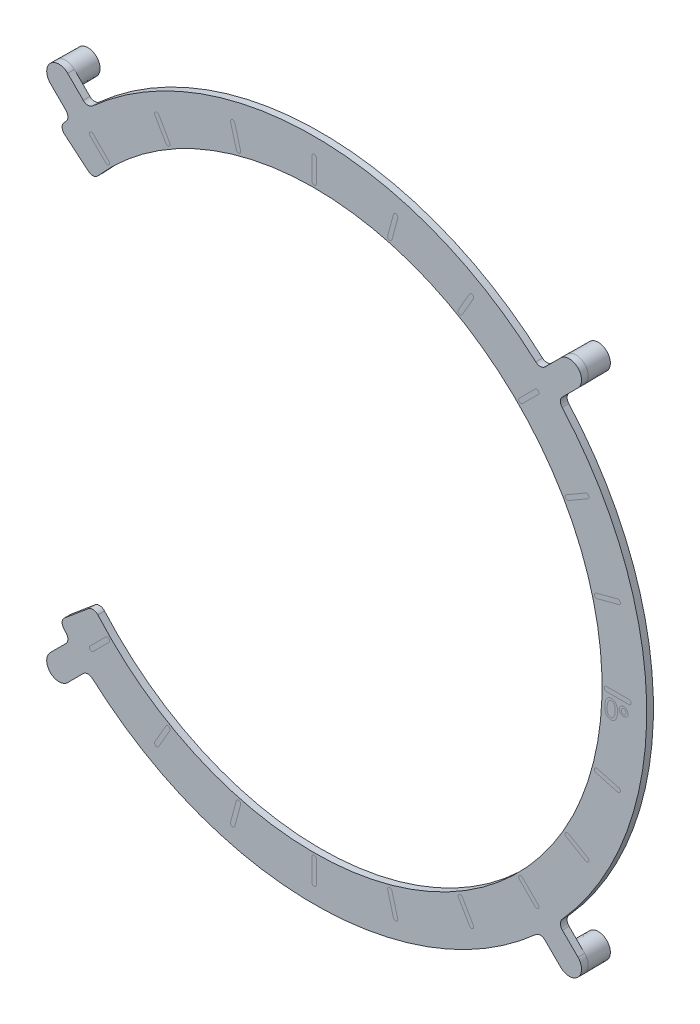
from build123d import *

# Parameters (mm, degrees)
RING_DEPTH               = 3
MAIN_FEATURES_SKETCH_3_R = 5.5
PEGS_DEPTH               = 10
PEGS_DRAFT               = -0.5
PEGS_PROFILE_2_DEPTH     = 10
PEGS_PROFILE_2_DRAFT     = -0.5
PEGS_PROFILE_3_DEPTH     = 10
PEGS_PROFILE_3_DRAFT     = -0.5
PEGS_PROFILE_4_DEPTH     = 10
PEGS_PROFILE_4_DRAFT     = -0.5
FILLET1_R                = 3
CUT_TICKS_DEPTH          = 1
EXTRUDE_TICKS_DEPTH      = 1
EXTRUDE_TICKS_2_DEPTH    = 1
EXTRUDE_TICKS_3_DEPTH    = 1
EXTRUDE_TICKS_4_DEPTH    = 1
EXTRUDE_TICKS_5_DEPTH    = 1
EXTRUDE_TICKS_6_DEPTH    = 1
EXTRUDE_TICKS_7_DEPTH    = 1
EXTRUDE_TICKS_8_DEPTH    = 1
EXTRUDE_TICKS_9_DEPTH    = 1
EXTRUDE_TICKS_10_DEPTH   = 1
EXTRUDE_TICKS_11_DEPTH   = 1
EXTRUDE_TICKS_12_DEPTH   = 1
EXTRUDE_TICKS_13_DEPTH   = 1
EXTRUDE_TICKS_14_DEPTH   = 1
EXTRUDE_TICKS_15_DEPTH   = 1
EXTRUDE_TICKS_16_DEPTH   = 1
EXTRUDE_TICKS_17_DEPTH   = 1
EXTRUDE_TICKS_18_DEPTH   = 1
EXTRUDE_TICKS_19_DEPTH   = 1
CUT_NUMBERS_DEPTH        = 1
EXTRUDE_NUMBERS_DEPTH    = 1
EXTRUDE_NUMBERS_2_DEPTH  = 1


with BuildPart() as part:
    # main_features_sketch → ring (new body)
    with BuildSketch(Plane.XY):
        with BuildLine():
            ThreePointArc((-98.819733162, 82.91960165), (129, 0), (-98.819733162, -82.91960165))
            Line((-98.819733162, -82.91960165), (-114.140622025, -95.775353843))
            ThreePointArc((-114.140622025, -95.775353843), (-111.693794635, -98.617930621), (-109.176194769, -101.398020176))
            Line((-109.176194769, -101.398020176), (-118.189087297, -110.410912703))
            ThreePointArc((-118.189087297, -110.410912703), (-118.189087297, -118.189087297), (-110.410912703, -118.189087297))
            Line((-110.410912703, -118.189087297), (-101.398020176, -109.176194769))
            ThreePointArc((-101.398020176, -109.176194769), (0, -149), (101.398020176, -109.176194769))
            Line((101.398020176, -109.176194769), (110.410912703, -118.189087297))
            ThreePointArc((110.410912703, -118.189087297), (118.189087297, -118.189087297), (118.189087297, -110.410912703))
            Line((118.189087297, -110.410912703), (109.176194769, -101.398020176))
            ThreePointArc((109.176194769, -101.398020176), (149, 0), (109.176194769, 101.398020176))
            Line((109.176194769, 101.398020176), (118.189087297, 110.410912703))
            ThreePointArc((118.189087297, 110.410912703), (118.189087297, 118.189087297), (110.410912703, 118.189087297))
            Line((110.410912703, 118.189087297), (101.398020176, 109.176194769))
            ThreePointArc((101.398020176, 109.176194769), (0, 149), (-101.398020176, 109.176194769))
            Line((-101.398020176, 109.176194769), (-110.410912703, 118.189087297))
            ThreePointArc((-110.410912703, 118.189087297), (-118.189087297, 118.189087297), (-118.189087297, 110.410912703))
            Line((-118.189087297, 110.410912703), (-109.176194769, 101.398020176))
            ThreePointArc((-109.176194769, 101.398020176), (-111.693794635, 98.617930621), (-114.140622025, 95.775353843))
            Line((-114.140622025, 95.775353843), (-98.819733162, 82.91960165))
        make_face()
    extrude(amount=RING_DEPTH)


with BuildPart() as pegs_tool:
    # main_features_sketch_3 → pegs (with draft: the straight prism first)
    with BuildSketch(Plane.XY):
        with Locations((-114.3, -114.3)):
            Circle(MAIN_FEATURES_SKETCH_3_R)
    extrude(amount=-PEGS_DEPTH)
    # pegs: the draft: its side faces are tilted about the plane it starts from
    pegs_sides = [pegs_tool.faces().sort_by_distance(p)[0] for p in [
        (-119.8, -114.3, -5),
    ]]
    draft(pegs_sides, Plane.XY, PEGS_DRAFT)


with BuildPart() as part_1:
    add(part.part)

    # pegs: add pegs_tool
    add(pegs_tool.part)


with BuildPart() as pegs_profile_2_tool:
    # main_features_sketch_3 → pegs profile 2 (with draft: the straight prism first)
    with BuildSketch(Plane.XY):
        with Locations((-114.3, 114.3)):
            Circle(MAIN_FEATURES_SKETCH_3_R)
    extrude(amount=-PEGS_PROFILE_2_DEPTH)
    # pegs profile 2: the draft: its side faces are tilted about the plane it starts from
    pegs_profile_2_sides = [pegs_profile_2_tool.faces().sort_by_distance(p)[0] for p in [
        (-119.8, 114.3, -5),
    ]]
    draft(pegs_profile_2_sides, Plane.XY, PEGS_PROFILE_2_DRAFT)


with BuildPart() as part_2:
    add(part_1.part)

    # pegs profile 2: add pegs_profile_2_tool
    add(pegs_profile_2_tool.part)


with BuildPart() as pegs_profile_3_tool:
    # main_features_sketch_3 → pegs profile 3 (with draft: the straight prism first)
    with BuildSketch(Plane.XY):
        with Locations((114.3, -114.3)):
            Circle(MAIN_FEATURES_SKETCH_3_R)
    extrude(amount=-PEGS_PROFILE_3_DEPTH)
    # pegs profile 3: the draft: its side faces are tilted about the plane it starts from
    pegs_profile_3_sides = [pegs_profile_3_tool.faces().sort_by_distance(p)[0] for p in [
        (108.8, -114.3, -5),
    ]]
    draft(pegs_profile_3_sides, Plane.XY, PEGS_PROFILE_3_DRAFT)


with BuildPart() as part_3:
    add(part_2.part)

    # pegs profile 3: add pegs_profile_3_tool
    add(pegs_profile_3_tool.part)


with BuildPart() as pegs_profile_4_tool:
    # main_features_sketch_3 → pegs profile 4 (with draft: the straight prism first)
    with BuildSketch(Plane.XY):
        with Locations((114.3, 114.3)):
            Circle(MAIN_FEATURES_SKETCH_3_R)
    extrude(amount=-PEGS_PROFILE_4_DEPTH)
    # pegs profile 4: the draft: its side faces are tilted about the plane it starts from
    pegs_profile_4_sides = [pegs_profile_4_tool.faces().sort_by_distance(p)[0] for p in [
        (108.8, 114.3, -5),
    ]]
    draft(pegs_profile_4_sides, Plane.XY, PEGS_PROFILE_4_DRAFT)


with BuildPart() as part_4:
    add(part_3.part)

    # pegs profile 4: add pegs_profile_4_tool
    add(pegs_profile_4_tool.part)

    # Fillet1
    fillet1_edges = [part_4.edges().sort_by_distance(p)[0] for p in [
        (-98.819733162, -82.91960165, 1.5),
        (-114.140622025, -95.775353843, 1.5),
        (-109.176194769, -101.398020176, 1.5),
        (-101.398020176, -109.176194769, 1.5),
        (101.398020176, -109.176194769, 1.5),
        (109.176194769, -101.398020176, 1.5),
        (109.176194769, 101.398020176, 1.5),
        (101.398020176, 109.176194769, 1.5),
        (-98.819733162, 82.91960165, 1.5),
        (-114.140622025, 95.775353843, 1.5),
        (-101.398020176, 109.176194769, 1.5),
        (-109.176194769, 101.398020176, 1.5),
    ]]
    fillet(fillet1_edges, radius=FILLET1_R)

    # tick_marks → cut_ticks (cut)
    with BuildSketch(Plane.XY.offset(3)):
        with BuildLine():
            Line((-93.338095117, 91.923881554), (-100.409162928, 98.994949366))
            ThreePointArc((-100.409162928, 98.994949366), (-100.409162928, 100.409162928), (-98.994949366, 100.409162928))
            Line((-98.994949366, 100.409162928), (-91.923881554, 93.338095117))
            ThreePointArc((-91.923881554, 93.338095117), (-91.923881554, 91.923881554), (-93.338095117, 91.923881554))
        make_face()
        with BuildLine():
            Line((-66.366025404, 112.949327896), (-71.366025404, 121.609581934))
            ThreePointArc((-71.366025404, 121.609581934), (-71, 122.975607337), (-69.633974596, 122.609581934))
            Line((-69.633974596, 122.609581934), (-64.633974596, 113.949327896))
            ThreePointArc((-64.633974596, 113.949327896), (-65, 112.583302492), (-66.366025404, 112.949327896))
        make_face()
        with BuildLine():
            Line((-34.871220735, 126.277464199), (-37.459411186, 135.936722462))
            ThreePointArc((-37.459411186, 135.936722462), (-36.752304405, 137.161467333), (-35.527559533, 136.454360552))
            Line((-35.527559533, 136.454360552), (-32.939369082, 126.795102289))
            ThreePointArc((-32.939369082, 126.795102289), (-33.646475863, 125.570357418), (-34.871220735, 126.277464199))
        make_face()
        with BuildLine():
            Line((-1, 131), (-1, 141))
            ThreePointArc((-1, 141), (0, 142), (1, 141))
            Line((1, 141), (1, 131))
            ThreePointArc((1, 131), (0, 130), (-1, 131))
        make_face()
        with BuildLine():
            Line((32.939369082, 126.795102289), (35.527559533, 136.454360552))
            ThreePointArc((35.527559533, 136.454360552), (36.752304405, 137.161467333), (37.459411186, 135.936722462))
            Line((37.459411186, 135.936722462), (34.871220735, 126.277464199))
            ThreePointArc((34.871220735, 126.277464199), (33.646475863, 125.570357418), (32.939369082, 126.795102289))
        make_face()
        with BuildLine():
            Line((64.633974596, 113.949327896), (69.633974596, 122.609581934))
            ThreePointArc((69.633974596, 122.609581934), (71, 122.975607337), (71.366025404, 121.609581934))
            Line((71.366025404, 121.609581934), (66.366025404, 112.949327896))
            ThreePointArc((66.366025404, 112.949327896), (65, 112.583302492), (64.633974596, 113.949327896))
        make_face()
        with BuildLine():
            Line((91.923881554, 93.338095117), (98.994949366, 100.409162928))
            ThreePointArc((98.994949366, 100.409162928), (100.409162928, 100.409162928), (100.409162928, 98.994949366))
            Line((100.409162928, 98.994949366), (93.338095117, 91.923881554))
            ThreePointArc((93.338095117, 91.923881554), (91.923881554, 91.923881554), (91.923881554, 93.338095117))
        make_face()
        with BuildLine():
            Line((112.949327896, 66.366025404), (121.609581934, 71.366025404))
            ThreePointArc((121.609581934, 71.366025404), (122.975607337, 71), (122.609581934, 69.633974596))
            Line((122.609581934, 69.633974596), (113.949327896, 64.633974596))
            ThreePointArc((113.949327896, 64.633974596), (112.583302492, 65), (112.949327896, 66.366025404))
        make_face()
        with BuildLine():
            Line((126.277464199, 34.871220735), (135.936722462, 37.459411186))
            ThreePointArc((135.936722462, 37.459411186), (137.161467333, 36.752304405), (136.454360552, 35.527559533))
            Line((136.454360552, 35.527559533), (126.795102289, 32.939369082))
            ThreePointArc((126.795102289, 32.939369082), (125.570357418, 33.646475863), (126.277464199, 34.871220735))
        make_face()
        with BuildLine():
            Line((131, 1), (141, 1))
            ThreePointArc((141, 1), (142, 0), (141, -1))
            Line((141, -1), (131, -1))
            ThreePointArc((131, -1), (130, 0), (131, 1))
        make_face()
        with BuildLine():
            Line((126.795102289, -32.939369082), (136.454360552, -35.527559533))
            ThreePointArc((136.454360552, -35.527559533), (137.161467333, -36.752304405), (135.936722462, -37.459411186))
            Line((135.936722462, -37.459411186), (126.277464199, -34.871220735))
            ThreePointArc((126.277464199, -34.871220735), (125.570357418, -33.646475863), (126.795102289, -32.939369082))
        make_face()
        with BuildLine():
            Line((113.949327896, -64.633974596), (122.609581934, -69.633974596))
            ThreePointArc((122.609581934, -69.633974596), (122.975607337, -71), (121.609581934, -71.366025404))
            Line((121.609581934, -71.366025404), (112.949327896, -66.366025404))
            ThreePointArc((112.949327896, -66.366025404), (112.583302492, -65), (113.949327896, -64.633974596))
        make_face()
        with BuildLine():
            Line((93.338095117, -91.923881554), (100.409162928, -98.994949366))
            ThreePointArc((100.409162928, -98.994949366), (100.409162928, -100.409162928), (98.994949366, -100.409162928))
            Line((98.994949366, -100.409162928), (91.923881554, -93.338095117))
            ThreePointArc((91.923881554, -93.338095117), (91.923881554, -91.923881554), (93.338095117, -91.923881554))
        make_face()
        with BuildLine():
            Line((66.366025404, -112.949327896), (71.366025404, -121.609581934))
            ThreePointArc((71.366025404, -121.609581934), (71, -122.975607337), (69.633974596, -122.609581934))
            Line((69.633974596, -122.609581934), (64.633974596, -113.949327896))
            ThreePointArc((64.633974596, -113.949327896), (65, -112.583302492), (66.366025404, -112.949327896))
        make_face()
        with BuildLine():
            Line((34.871220735, -126.277464199), (37.459411186, -135.936722462))
            ThreePointArc((37.459411186, -135.936722462), (36.752304405, -137.161467333), (35.527559533, -136.454360552))
            Line((35.527559533, -136.454360552), (32.939369082, -126.795102289))
            ThreePointArc((32.939369082, -126.795102289), (33.646475863, -125.570357418), (34.871220735, -126.277464199))
        make_face()
        with BuildLine():
            Line((1, -131), (1, -141))
            ThreePointArc((1, -141), (0, -142), (-1, -141))
            Line((-1, -141), (-1, -131))
            ThreePointArc((-1, -131), (0, -130), (1, -131))
        make_face()
        with BuildLine():
            Line((-32.939369082, -126.795102289), (-35.527559533, -136.454360552))
            ThreePointArc((-35.527559533, -136.454360552), (-36.752304405, -137.161467333), (-37.459411186, -135.936722462))
            Line((-37.459411186, -135.936722462), (-34.871220735, -126.277464199))
            ThreePointArc((-34.871220735, -126.277464199), (-33.646475863, -125.570357418), (-32.939369082, -126.795102289))
        make_face()
        with BuildLine():
            Line((-64.633974596, -113.949327896), (-69.633974596, -122.609581934))
            ThreePointArc((-69.633974596, -122.609581934), (-71, -122.975607337), (-71.366025404, -121.609581934))
            Line((-71.366025404, -121.609581934), (-66.366025404, -112.949327896))
            ThreePointArc((-66.366025404, -112.949327896), (-65, -112.583302492), (-64.633974596, -113.949327896))
        make_face()
        with BuildLine():
            Line((-91.923881554, -93.338095117), (-98.994949366, -100.409162928))
            ThreePointArc((-98.994949366, -100.409162928), (-100.409162928, -100.409162928), (-100.409162928, -98.994949366))
            Line((-100.409162928, -98.994949366), (-93.338095117, -91.923881554))
            ThreePointArc((-93.338095117, -91.923881554), (-91.923881554, -91.923881554), (-91.923881554, -93.338095117))
        make_face()
    extrude(amount=-CUT_TICKS_DEPTH, mode=Mode.SUBTRACT)

    # numbers_sketch → cut_numbers (cut)
    # profile 1 of 2: a face of its own
    with BuildSketch(Plane.XY.offset(3)):
        with BuildLine():
            add(Edge.make_bspline(
                [(130.247849847, -6.530142484), (130.259435363, -6.403469593), (130.281956239, -6.157232438), (130.326358515, -5.799510621), (130.381168679, -5.46451119), (130.442355031, -5.1518788), (130.515029315, -4.862814833), (130.594128584, -4.595899097), (130.683995641, -4.352014642), (130.782001058, -4.12854355), (130.890269218, -3.924103907), (131.005785678, -3.734961692), (131.127740313, -3.558505709), (131.259619838, -3.396759959), (131.398720167, -3.24721496), (131.546540196, -3.112007382), (131.702941503, -2.991527308), (131.866051533, -2.883833986), (132.035501194, -2.791899136), (132.208036711, -2.712073639), (132.384525467, -2.648197637), (132.564527725, -2.598227156), (132.748335202, -2.562873772), (132.935320966, -2.541751072), (133.126165442, -2.53729926), (133.253751824, -2.544250514), (133.318362667, -2.547770689)],
                knots=[0, 0, 0, 0, 1.61827603, 3.145737672, 4.584824523, 5.936336854, 7.197309618, 8.375551137, 9.476458172, 10.501880003, 11.477750075, 12.417205866, 13.320287874, 14.204452368, 15.069952981, 15.916623796, 16.749932666, 17.579324636, 18.400517487, 19.200339989, 19.995819531, 20.785617524, 21.574684155, 22.37473762, 23.176953122, 24, 24, 24, 24], degree=3))
            add(Edge.make_bspline(
                [(133.318362667, -2.547770689), (133.387940092, -2.554757524), (133.525714067, -2.568592528), (133.728496495, -2.607156697), (133.924047373, -2.662551136), (134.113647764, -2.729144897), (134.29542451, -2.811146872), (134.469524417, -2.908590774), (134.637917985, -3.018480634), (134.797906464, -3.144270734), (134.950544053, -3.281391991), (135.091373365, -3.432616918), (135.222039496, -3.595493891), (135.342123787, -3.770875134), (135.453483832, -3.958015713), (135.550207869, -4.159466414), (135.63869308, -4.371748217), (135.718110412, -4.596510255), (135.783160952, -4.837201101), (135.838549624, -5.093720763), (135.87670579, -5.368100731), (135.906727666, -5.659338124), (135.919992298, -5.968042543), (135.920742748, -6.294076198), (135.912395875, -6.637354245), (135.894731769, -6.871544848), (135.88567036, -6.991680945)],
                knots=[0, 0, 0, 0, 0.871311131, 1.725329718, 2.568587105, 3.402540465, 4.227998323, 5.05060485, 5.887158929, 6.731572112, 7.584785719, 8.44212009, 9.304147133, 10.185097487, 11.089488333, 12.01557912, 12.967704211, 13.955299893, 14.984247638, 16.073349664, 17.224008303, 18.435090282, 19.721522675, 21.07315721, 22.498575664, 24, 24, 24, 24], degree=3))
            add(Edge.make_bspline(
                [(135.88567036, -6.991680945), (135.87479058, -7.111433308), (135.853622099, -7.344432114), (135.808150516, -7.683801219), (135.754498147, -8.003626595), (135.690263875, -8.304664383), (135.616825808, -8.586557955), (135.534820573, -8.84998105), (135.438847324, -9.092572725), (135.33733295, -9.318194204), (135.223423739, -9.525855289), (135.103669775, -9.720872102), (134.973777637, -9.901606703), (134.836110104, -10.069655895), (134.687111833, -10.22168589), (134.532441813, -10.36391007), (134.366830345, -10.490301351), (134.193660138, -10.602639646), (134.013959435, -10.700182365), (133.829586648, -10.78437933), (133.639932775, -10.850995812), (133.446407353, -10.905127237), (133.247914075, -10.941455232), (133.045384402, -10.962357825), (132.838520935, -10.967298234), (132.699742911, -10.959024201), (132.629260103, -10.954821971)],
                knots=[0, 0, 0, 0, 1.499152549, 2.916858956, 4.268090621, 5.541798329, 6.75344151, 7.899374152, 8.979171957, 10.00447148, 10.982037653, 11.930231764, 12.856270518, 13.75513052, 14.635967874, 15.508302836, 16.372898767, 17.230125775, 18.079580563, 18.920215607, 19.754467163, 20.583410652, 21.423412171, 22.267102547, 23.119893245, 24, 24, 24, 24], degree=3))
            add(Edge.make_bspline(
                [(132.629260103, -10.954821971), (132.564456808, -10.948498714), (132.436738356, -10.936036438), (132.24956895, -10.897456399), (132.068054374, -10.848766349), (131.893081397, -10.784046791), (131.724081193, -10.706450737), (131.560161102, -10.617603367), (131.404002808, -10.511730075), (131.25372322, -10.394295281), (131.112388011, -10.261708946), (130.979545005, -10.118091256), (130.856405818, -9.961299831), (130.745499206, -9.790719069), (130.640015566, -9.609903088), (130.548071068, -9.415188381), (130.463963446, -9.208895706), (130.390118693, -8.988531822), (130.326932554, -8.751103431), (130.277982734, -8.494002622), (130.241341289, -8.216293828), (130.218544477, -7.918313275), (130.20473238, -7.600252795), (130.208234406, -7.261870953), (130.220018393, -6.902662908), (130.238394951, -6.656695046), (130.247849847, -6.530142484)],
                knots=[0, 0, 0, 0, 0.828437702, 1.632737654, 2.42967114, 3.219345181, 4.004554763, 4.795954934, 5.590097458, 6.403746225, 7.221817338, 8.054487758, 8.892584602, 9.756526925, 10.643140985, 11.55574709, 12.495399042, 13.478287074, 14.512653996, 15.621085901, 16.808049767, 18.077183614, 19.424923863, 20.859997346, 22.384441863, 24, 24, 24, 24], degree=3))
        make_face()
        with BuildLine():
            add(Edge.make_bspline(
                [(131.292721642, -6.631104022), (131.28477992, -6.737910983), (131.269382673, -6.944986108), (131.25459966, -7.246337634), (131.249374469, -7.528005474), (131.254212577, -7.789378752), (131.266793287, -8.030464885), (131.286683691, -8.251482431), (131.316739715, -8.452803405), (131.356925286, -8.635255481), (131.405956699, -8.802366562), (131.460480848, -8.957275101), (131.518809789, -9.10274443), (131.587059103, -9.236021753), (131.660081725, -9.359772425), (131.740979543, -9.472492821), (131.827042298, -9.575610218), (131.949485678, -9.694946681), (132.110097593, -9.820135734), (132.311713463, -9.935468713), (132.518229181, -10.015352986), (132.660158763, -10.034910892), (132.730221642, -10.044565561)],
                knots=[0, 0, 0, 0, 1.562818808, 3.029960774, 4.40208351, 5.672886883, 6.843801576, 7.924276773, 8.909845954, 9.811982668, 10.648232427, 11.449452758, 12.207976657, 12.933081093, 13.632246986, 14.302799925, 14.955536824, 15.589430577, 16.794738237, 17.915324831, 18.970909793, 20, 20, 20, 20], degree=3))
            add(Edge.make_bspline(
                [(132.730221642, -10.044565561), (132.811050679, -10.047619097), (132.971788916, -10.053691421), (133.211816457, -10.008101791), (133.446049671, -9.926027653), (133.633444874, -9.823758572), (133.778602522, -9.723991846), (133.883046034, -9.634662025), (133.982736116, -9.535479424), (134.075767197, -9.423879353), (134.163508035, -9.301946178), (134.247645318, -9.169616626), (134.32584787, -9.026129116), (134.371878597, -8.924679488), (134.395285744, -8.873091202)],
                knots=[0, 0, 0, 0, 1.331768172, 2.648380761, 4.004028281, 5.416743492, 6.158066992, 6.909033705, 7.682352155, 8.477345272, 9.304749422, 10.161119474, 11.064908395, 12, 12, 12, 12], degree=3))
            add(Edge.make_bspline(
                [(134.395285744, -8.873091202), (134.424437914, -8.805044135), (134.483471319, -8.667248211), (134.557922605, -8.450389586), (134.626708345, -8.223844279), (134.688294147, -7.985617854), (134.738854639, -7.735621101), (134.781225821, -7.474588221), (134.819703291, -7.202852125), (134.835791851, -7.017418695), (134.844003693, -6.922770689)],
                knots=[0, 0, 0, 0, 0.883430991, 1.788955713, 2.735063933, 3.709438727, 4.72492913, 5.778506935, 6.866116603, 8, 8, 8, 8], degree=3))
            add(Edge.make_bspline(
                [(134.844003693, -6.922770689), (134.851103131, -6.828257802), (134.864969864, -6.64365375), (134.873709603, -6.373165985), (134.876386913, -6.11555067), (134.86787141, -5.870745012), (134.852608077, -5.638102235), (134.827437212, -5.418713513), (134.791580864, -5.212443577), (134.749082217, -5.018596941), (134.69705082, -4.837068702), (134.640509196, -4.66680481), (134.573997308, -4.509365326), (134.502609593, -4.36329577), (134.423516387, -4.229566617), (134.339005199, -4.107433605), (134.247036631, -3.997136325), (134.116799505, -3.869984638), (133.944635744, -3.736224846), (133.727051925, -3.612467068), (133.50007645, -3.528059555), (133.343574914, -3.506998469), (133.265478052, -3.496488638)],
                knots=[0, 0, 0, 0, 1.357865668, 2.652204481, 3.876866366, 5.048551581, 6.161015914, 7.216739124, 8.210814996, 9.159724225, 10.058636074, 10.915472518, 11.728562328, 12.505583417, 13.243310273, 13.952492572, 14.631630308, 15.297351225, 16.557379802, 17.743155118, 18.873796981, 20, 20, 20, 20], degree=3))
            add(Edge.make_bspline(
                [(133.265478052, -3.496488638), (133.194273069, -3.495026174), (133.050624281, -3.492075803), (132.833369163, -3.534923422), (132.617078694, -3.616817065), (132.441028499, -3.715419587), (132.301367285, -3.811035844), (132.200658471, -3.898336419), (132.104377543, -3.996992509), (132.011109656, -4.105358517), (131.924374985, -4.227257476), (131.841591908, -4.360343558), (131.761030173, -4.50407286), (131.686884278, -4.661567376), (131.61704085, -4.835174682), (131.553386473, -5.028938426), (131.49661813, -5.244332434), (131.443185207, -5.480421437), (131.397970387, -5.738406918), (131.355878319, -6.017227168), (131.321204333, -6.317170633), (131.302418773, -6.524223207), (131.292721642, -6.631104022)],
                knots=[0, 0, 0, 0, 1.037413375, 2.092875636, 3.208354798, 4.402221346, 5.029658683, 5.676805883, 6.344129212, 7.041189164, 7.761973708, 8.525859314, 9.328838035, 10.166119681, 11.065501841, 12.059435704, 13.141589609, 14.316608638, 15.592490277, 16.964620918, 18.433133255, 20, 20, 20, 20], degree=3))
        make_face(mode=Mode.SUBTRACT)
    # profile 2 of 2: a face of its own
    with BuildSketch(Plane.XY.offset(3)):
        with BuildLine():
            add(Edge.make_bspline(
                [(140.640846808, -5.083838614), (140.633383432, -5.147562419), (140.618591458, -5.273859266), (140.57766023, -5.45869898), (140.514810374, -5.634381204), (140.439301208, -5.803853851), (140.34095109, -5.96325836), (140.227677777, -6.115436223), (140.095943209, -6.259576437), (139.948976911, -6.393630193), (139.789189417, -6.515781224), (139.619421776, -6.619781176), (139.4419086, -6.705676525), (139.256534952, -6.771788407), (139.063492644, -6.817646528), (138.862986835, -6.847119571), (138.65468573, -6.856574516), (138.513684624, -6.848934), (138.442128859, -6.845056563)],
                knots=[0, 0, 0, 0, 0.981834128, 1.945937709, 2.889855742, 3.833915441, 4.780521496, 5.750329985, 6.734374955, 7.764627895, 8.791695718, 9.808458087, 10.806904893, 11.805251239, 12.814753756, 13.839344671, 14.903502628, 16, 16, 16, 16], degree=3))
            add(Edge.make_bspline(
                [(138.442128859, -6.845056563), (138.3762364, -6.83771889), (138.246154529, -6.823233193), (138.056818787, -6.780855519), (137.876085319, -6.723594766), (137.705094317, -6.647934942), (137.544275675, -6.553712959), (137.390934658, -6.444868658), (137.248328695, -6.31727615), (137.115896638, -6.175105874), (136.99651935, -6.021639253), (136.895204612, -5.858574152), (136.810876705, -5.689942624), (136.746570779, -5.513467071), (136.700053627, -5.330333692), (136.671588582, -5.140351196), (136.659170472, -4.943360499), (136.66720125, -4.810319714), (136.671295526, -4.74249246)],
                knots=[0, 0, 0, 0, 1.037515882, 2.048216267, 3.032259203, 4.002157969, 4.969130722, 5.946359887, 6.941784324, 7.959727494, 8.985339925, 9.981045476, 10.961134342, 11.932330728, 12.916267007, 13.914709271, 14.93687081, 16, 16, 16, 16], degree=3))
            add(Edge.make_bspline(
                [(136.671295526, -4.74249246), (136.677767486, -4.677606349), (136.690509742, -4.549855943), (136.735993984, -4.36464513), (136.794257544, -4.187484416), (136.872098918, -4.019423224), (136.967542562, -3.860636827), (137.077903886, -3.708274039), (137.20939817, -3.56790073), (137.354025972, -3.435307735), (137.510576958, -3.316527414), (137.67502347, -3.215010643), (137.844373516, -3.130854419), (138.019683514, -3.064358268), (138.20106051, -3.018529045), (138.387169616, -2.989494599), (138.578874754, -2.977186556), (138.708171714, -2.985210735), (138.773859629, -2.989287332)],
                knots=[0, 0, 0, 0, 1.027633626, 2.023246725, 3.001404518, 3.966806442, 4.93815026, 5.920944928, 6.929002123, 7.967089793, 9.013899898, 10.024350194, 11.011903836, 11.993432784, 12.976697161, 13.957755568, 14.962459916, 16, 16, 16, 16], degree=3))
            add(Edge.make_bspline(
                [(138.773859629, -2.989287332), (138.844609543, -2.996288336), (138.983518872, -3.010034001), (139.1848429, -3.056791183), (139.376320244, -3.117518385), (139.558778832, -3.19383836), (139.729342691, -3.2908165), (139.888439224, -3.405806434), (140.038605181, -3.535702465), (140.175042957, -3.682664608), (140.296750208, -3.839971585), (140.404410463, -4.002307927), (140.491172872, -4.17117685), (140.558225053, -4.344967655), (140.6092626, -4.522819156), (140.639141832, -4.705618981), (140.650912798, -4.893620809), (140.644238443, -5.019746629), (140.640846808, -5.083838614)],
                knots=[0, 0, 0, 0, 1.092231102, 2.144470277, 3.170607154, 4.179101014, 5.179634945, 6.180371174, 7.193437818, 8.227924729, 9.258163217, 10.249244673, 11.219129963, 12.17100311, 13.109778343, 14.05913166, 15.013730062, 16, 16, 16, 16], degree=3))
        make_face()
        with BuildLine():
            add(Edge.make_bspline(
                [(139.701744244, -5.018133486), (139.704876527, -4.937324657), (139.710962569, -4.780312662), (139.667640538, -4.551312289), (139.582926193, -4.340714373), (139.459309251, -4.152824167), (139.307022574, -3.992054538), (139.129030317, -3.869780827), (138.93055216, -3.785174599), (138.788552121, -3.766456914), (138.716167321, -3.756915537)],
                knots=[0, 0, 0, 0, 1.086947956, 2.111945782, 3.113135014, 4.127384682, 5.12523017, 6.077643061, 7.020074749, 8, 8, 8, 8], degree=3))
            add(Edge.make_bspline(
                [(138.716167321, -3.756915537), (138.652843959, -3.755479323), (138.526415764, -3.75261185), (138.339036648, -3.803615965), (138.158200287, -3.892310574), (137.987706306, -4.019404255), (137.836632603, -4.180247948), (137.718806256, -4.373320705), (137.64099883, -4.595277278), (137.620819797, -4.753648457), (137.61039809, -4.835441178)],
                knots=[0, 0, 0, 0, 0.884197212, 1.765343047, 2.689991306, 3.696769463, 4.730306579, 5.76576923, 6.846104338, 8, 8, 8, 8], degree=3))
            add(Edge.make_bspline(
                [(137.61039809, -4.835441178), (137.607117392, -4.916827006), (137.60078455, -5.073928825), (137.645469332, -5.302187887), (137.726047904, -5.513264337), (137.853237266, -5.696282558), (138.000040352, -5.852038311), (138.163365805, -5.969745434), (138.336399187, -6.052730607), (138.459455761, -6.07029551), (138.5206545, -6.079030922)],
                knots=[0, 0, 0, 0, 1.144565006, 2.209392605, 3.253925162, 4.306514957, 5.32904796, 6.256924028, 7.133129998, 8, 8, 8, 8], degree=3))
            add(Edge.make_bspline(
                [(138.5206545, -6.079030922), (138.593009269, -6.081193711), (138.735175488, -6.085443267), (138.944151316, -6.035710353), (139.139915995, -5.944171585), (139.317850371, -5.8104264), (139.471562134, -5.646426051), (139.592168257, -5.456911549), (139.670391656, -5.244511796), (139.691156171, -5.094583636), (139.701744244, -5.018133486)],
                knots=[0, 0, 0, 0, 0.982689701, 1.930837199, 2.894666778, 3.909290256, 4.94438296, 5.941946532, 6.950574092, 8, 8, 8, 8], degree=3))
        make_face(mode=Mode.SUBTRACT)
    extrude(amount=-CUT_NUMBERS_DEPTH, mode=Mode.SUBTRACT)


with BuildPart() as body_2:
    # tick_marks_3 → extrude_ticks (new body)
    with BuildSketch(Plane.XY.offset(3)):
        with BuildLine():
            Line((-93.338095117, 91.923881554), (-100.409162928, 98.994949366))
            ThreePointArc((-100.409162928, 98.994949366), (-100.409162928, 100.409162928), (-98.994949366, 100.409162928))
            Line((-98.994949366, 100.409162928), (-91.923881554, 93.338095117))
            ThreePointArc((-91.923881554, 93.338095117), (-91.923881554, 91.923881554), (-93.338095117, 91.923881554))
        make_face()
    extrude(amount=-EXTRUDE_TICKS_DEPTH)


with BuildPart() as body_3:
    # tick_marks_3 → extrude_ticks 2 (new body)
    with BuildSketch(Plane.XY.offset(3)):
        with BuildLine():
            Line((-66.366025404, 112.949327896), (-71.366025404, 121.609581934))
            ThreePointArc((-71.366025404, 121.609581934), (-71, 122.975607337), (-69.633974596, 122.609581934))
            Line((-69.633974596, 122.609581934), (-64.633974596, 113.949327896))
            ThreePointArc((-64.633974596, 113.949327896), (-65, 112.583302492), (-66.366025404, 112.949327896))
        make_face()
    extrude(amount=-EXTRUDE_TICKS_2_DEPTH)


with BuildPart() as body_4:
    # tick_marks_3 → extrude_ticks 3 (new body)
    with BuildSketch(Plane.XY.offset(3)):
        with BuildLine():
            Line((-34.871220735, 126.277464199), (-37.459411186, 135.936722462))
            ThreePointArc((-37.459411186, 135.936722462), (-36.752304405, 137.161467333), (-35.527559533, 136.454360552))
            Line((-35.527559533, 136.454360552), (-32.939369082, 126.795102289))
            ThreePointArc((-32.939369082, 126.795102289), (-33.646475863, 125.570357418), (-34.871220735, 126.277464199))
        make_face()
    extrude(amount=-EXTRUDE_TICKS_3_DEPTH)


with BuildPart() as body_5:
    # tick_marks_3 → extrude_ticks 4 (new body)
    with BuildSketch(Plane.XY.offset(3)):
        with BuildLine():
            Line((-1, 131), (-1, 141))
            ThreePointArc((-1, 141), (0, 142), (1, 141))
            Line((1, 141), (1, 131))
            ThreePointArc((1, 131), (0, 130), (-1, 131))
        make_face()
    extrude(amount=-EXTRUDE_TICKS_4_DEPTH)


with BuildPart() as body_6:
    # tick_marks_3 → extrude_ticks 5 (new body)
    with BuildSketch(Plane.XY.offset(3)):
        with BuildLine():
            Line((32.939369082, 126.795102289), (35.527559533, 136.454360552))
            ThreePointArc((35.527559533, 136.454360552), (36.752304405, 137.161467333), (37.459411186, 135.936722462))
            Line((37.459411186, 135.936722462), (34.871220735, 126.277464199))
            ThreePointArc((34.871220735, 126.277464199), (33.646475863, 125.570357418), (32.939369082, 126.795102289))
        make_face()
    extrude(amount=-EXTRUDE_TICKS_5_DEPTH)


with BuildPart() as body_7:
    # tick_marks_3 → extrude_ticks 6 (new body)
    with BuildSketch(Plane.XY.offset(3)):
        with BuildLine():
            Line((64.633974596, 113.949327896), (69.633974596, 122.609581934))
            ThreePointArc((69.633974596, 122.609581934), (71, 122.975607337), (71.366025404, 121.609581934))
            Line((71.366025404, 121.609581934), (66.366025404, 112.949327896))
            ThreePointArc((66.366025404, 112.949327896), (65, 112.583302492), (64.633974596, 113.949327896))
        make_face()
    extrude(amount=-EXTRUDE_TICKS_6_DEPTH)


with BuildPart() as body_8:
    # tick_marks_3 → extrude_ticks 7 (new body)
    with BuildSketch(Plane.XY.offset(3)):
        with BuildLine():
            Line((91.923881554, 93.338095117), (98.994949366, 100.409162928))
            ThreePointArc((98.994949366, 100.409162928), (100.409162928, 100.409162928), (100.409162928, 98.994949366))
            Line((100.409162928, 98.994949366), (93.338095117, 91.923881554))
            ThreePointArc((93.338095117, 91.923881554), (91.923881554, 91.923881554), (91.923881554, 93.338095117))
        make_face()
    extrude(amount=-EXTRUDE_TICKS_7_DEPTH)


with BuildPart() as body_9:
    # tick_marks_3 → extrude_ticks 8 (new body)
    with BuildSketch(Plane.XY.offset(3)):
        with BuildLine():
            Line((112.949327896, 66.366025404), (121.609581934, 71.366025404))
            ThreePointArc((121.609581934, 71.366025404), (122.975607337, 71), (122.609581934, 69.633974596))
            Line((122.609581934, 69.633974596), (113.949327896, 64.633974596))
            ThreePointArc((113.949327896, 64.633974596), (112.583302492, 65), (112.949327896, 66.366025404))
        make_face()
    extrude(amount=-EXTRUDE_TICKS_8_DEPTH)


with BuildPart() as body_10:
    # tick_marks_3 → extrude_ticks 9 (new body)
    with BuildSketch(Plane.XY.offset(3)):
        with BuildLine():
            Line((126.277464199, 34.871220735), (135.936722462, 37.459411186))
            ThreePointArc((135.936722462, 37.459411186), (137.161467333, 36.752304405), (136.454360552, 35.527559533))
            Line((136.454360552, 35.527559533), (126.795102289, 32.939369082))
            ThreePointArc((126.795102289, 32.939369082), (125.570357418, 33.646475863), (126.277464199, 34.871220735))
        make_face()
    extrude(amount=-EXTRUDE_TICKS_9_DEPTH)


with BuildPart() as body_11:
    # tick_marks_3 → extrude_ticks 10 (new body)
    with BuildSketch(Plane.XY.offset(3)):
        with BuildLine():
            Line((131, 1), (141, 1))
            ThreePointArc((141, 1), (142, 0), (141, -1))
            Line((141, -1), (131, -1))
            ThreePointArc((131, -1), (130, 0), (131, 1))
        make_face()
    extrude(amount=-EXTRUDE_TICKS_10_DEPTH)


with BuildPart() as body_12:
    # tick_marks_3 → extrude_ticks 11 (new body)
    with BuildSketch(Plane.XY.offset(3)):
        with BuildLine():
            Line((126.795102289, -32.939369082), (136.454360552, -35.527559533))
            ThreePointArc((136.454360552, -35.527559533), (137.161467333, -36.752304405), (135.936722462, -37.459411186))
            Line((135.936722462, -37.459411186), (126.277464199, -34.871220735))
            ThreePointArc((126.277464199, -34.871220735), (125.570357418, -33.646475863), (126.795102289, -32.939369082))
        make_face()
    extrude(amount=-EXTRUDE_TICKS_11_DEPTH)


with BuildPart() as body_13:
    # tick_marks_3 → extrude_ticks 12 (new body)
    with BuildSketch(Plane.XY.offset(3)):
        with BuildLine():
            Line((113.949327896, -64.633974596), (122.609581934, -69.633974596))
            ThreePointArc((122.609581934, -69.633974596), (122.975607337, -71), (121.609581934, -71.366025404))
            Line((121.609581934, -71.366025404), (112.949327896, -66.366025404))
            ThreePointArc((112.949327896, -66.366025404), (112.583302492, -65), (113.949327896, -64.633974596))
        make_face()
    extrude(amount=-EXTRUDE_TICKS_12_DEPTH)


with BuildPart() as body_14:
    # tick_marks_3 → extrude_ticks 13 (new body)
    with BuildSketch(Plane.XY.offset(3)):
        with BuildLine():
            Line((93.338095117, -91.923881554), (100.409162928, -98.994949366))
            ThreePointArc((100.409162928, -98.994949366), (100.409162928, -100.409162928), (98.994949366, -100.409162928))
            Line((98.994949366, -100.409162928), (91.923881554, -93.338095117))
            ThreePointArc((91.923881554, -93.338095117), (91.923881554, -91.923881554), (93.338095117, -91.923881554))
        make_face()
    extrude(amount=-EXTRUDE_TICKS_13_DEPTH)


with BuildPart() as body_15:
    # tick_marks_3 → extrude_ticks 14 (new body)
    with BuildSketch(Plane.XY.offset(3)):
        with BuildLine():
            Line((66.366025404, -112.949327896), (71.366025404, -121.609581934))
            ThreePointArc((71.366025404, -121.609581934), (71, -122.975607337), (69.633974596, -122.609581934))
            Line((69.633974596, -122.609581934), (64.633974596, -113.949327896))
            ThreePointArc((64.633974596, -113.949327896), (65, -112.583302492), (66.366025404, -112.949327896))
        make_face()
    extrude(amount=-EXTRUDE_TICKS_14_DEPTH)


with BuildPart() as body_16:
    # tick_marks_3 → extrude_ticks 15 (new body)
    with BuildSketch(Plane.XY.offset(3)):
        with BuildLine():
            Line((34.871220735, -126.277464199), (37.459411186, -135.936722462))
            ThreePointArc((37.459411186, -135.936722462), (36.752304405, -137.161467333), (35.527559533, -136.454360552))
            Line((35.527559533, -136.454360552), (32.939369082, -126.795102289))
            ThreePointArc((32.939369082, -126.795102289), (33.646475863, -125.570357418), (34.871220735, -126.277464199))
        make_face()
    extrude(amount=-EXTRUDE_TICKS_15_DEPTH)


with BuildPart() as body_17:
    # tick_marks_3 → extrude_ticks 16 (new body)
    with BuildSketch(Plane.XY.offset(3)):
        with BuildLine():
            Line((1, -131), (1, -141))
            ThreePointArc((1, -141), (0, -142), (-1, -141))
            Line((-1, -141), (-1, -131))
            ThreePointArc((-1, -131), (0, -130), (1, -131))
        make_face()
    extrude(amount=-EXTRUDE_TICKS_16_DEPTH)


with BuildPart() as body_18:
    # tick_marks_3 → extrude_ticks 17 (new body)
    with BuildSketch(Plane.XY.offset(3)):
        with BuildLine():
            Line((-32.939369082, -126.795102289), (-35.527559533, -136.454360552))
            ThreePointArc((-35.527559533, -136.454360552), (-36.752304405, -137.161467333), (-37.459411186, -135.936722462))
            Line((-37.459411186, -135.936722462), (-34.871220735, -126.277464199))
            ThreePointArc((-34.871220735, -126.277464199), (-33.646475863, -125.570357418), (-32.939369082, -126.795102289))
        make_face()
    extrude(amount=-EXTRUDE_TICKS_17_DEPTH)


with BuildPart() as body_19:
    # tick_marks_3 → extrude_ticks 18 (new body)
    with BuildSketch(Plane.XY.offset(3)):
        with BuildLine():
            Line((-64.633974596, -113.949327896), (-69.633974596, -122.609581934))
            ThreePointArc((-69.633974596, -122.609581934), (-71, -122.975607337), (-71.366025404, -121.609581934))
            Line((-71.366025404, -121.609581934), (-66.366025404, -112.949327896))
            ThreePointArc((-66.366025404, -112.949327896), (-65, -112.583302492), (-64.633974596, -113.949327896))
        make_face()
    extrude(amount=-EXTRUDE_TICKS_18_DEPTH)


with BuildPart() as body_20:
    # tick_marks_3 → extrude_ticks 19 (new body)
    with BuildSketch(Plane.XY.offset(3)):
        with BuildLine():
            Line((-91.923881554, -93.338095117), (-98.994949366, -100.409162928))
            ThreePointArc((-98.994949366, -100.409162928), (-100.409162928, -100.409162928), (-100.409162928, -98.994949366))
            Line((-100.409162928, -98.994949366), (-93.338095117, -91.923881554))
            ThreePointArc((-93.338095117, -91.923881554), (-91.923881554, -91.923881554), (-91.923881554, -93.338095117))
        make_face()
    extrude(amount=-EXTRUDE_TICKS_19_DEPTH)


with BuildPart() as body_21:
    # numbers_sketch_2 → extrude_numbers (new body)
    with BuildSketch(Plane.XY.offset(3)):
        with BuildLine():
            add(Edge.make_bspline(
                [(130.247849847, -6.530142484), (130.259435363, -6.403469593), (130.281956239, -6.157232438), (130.326358515, -5.799510621), (130.381168679, -5.46451119), (130.442355031, -5.1518788), (130.515029315, -4.862814833), (130.594128584, -4.595899097), (130.683995641, -4.352014642), (130.782001058, -4.12854355), (130.890269218, -3.924103907), (131.005785678, -3.734961692), (131.127740313, -3.558505709), (131.259619838, -3.396759959), (131.398720167, -3.24721496), (131.546540196, -3.112007382), (131.702941503, -2.991527308), (131.866051533, -2.883833986), (132.035501194, -2.791899136), (132.208036711, -2.712073639), (132.384525467, -2.648197637), (132.564527725, -2.598227156), (132.748335202, -2.562873772), (132.935320966, -2.541751072), (133.126165442, -2.53729926), (133.253751824, -2.544250514), (133.318362667, -2.547770689)],
                knots=[0, 0, 0, 0, 1.61827603, 3.145737672, 4.584824523, 5.936336854, 7.197309618, 8.375551137, 9.476458172, 10.501880003, 11.477750075, 12.417205866, 13.320287874, 14.204452368, 15.069952981, 15.916623796, 16.749932666, 17.579324636, 18.400517487, 19.200339989, 19.995819531, 20.785617524, 21.574684155, 22.37473762, 23.176953122, 24, 24, 24, 24], degree=3))
            add(Edge.make_bspline(
                [(133.318362667, -2.547770689), (133.387940092, -2.554757524), (133.525714067, -2.568592528), (133.728496495, -2.607156697), (133.924047373, -2.662551136), (134.113647764, -2.729144897), (134.29542451, -2.811146872), (134.469524417, -2.908590774), (134.637917985, -3.018480634), (134.797906464, -3.144270734), (134.950544053, -3.281391991), (135.091373365, -3.432616918), (135.222039496, -3.595493891), (135.342123787, -3.770875134), (135.453483832, -3.958015713), (135.550207869, -4.159466414), (135.63869308, -4.371748217), (135.718110412, -4.596510255), (135.783160952, -4.837201101), (135.838549624, -5.093720763), (135.87670579, -5.368100731), (135.906727666, -5.659338124), (135.919992298, -5.968042543), (135.920742748, -6.294076198), (135.912395875, -6.637354245), (135.894731769, -6.871544848), (135.88567036, -6.991680945)],
                knots=[0, 0, 0, 0, 0.871311131, 1.725329718, 2.568587105, 3.402540465, 4.227998323, 5.05060485, 5.887158929, 6.731572112, 7.584785719, 8.44212009, 9.304147133, 10.185097487, 11.089488333, 12.01557912, 12.967704211, 13.955299893, 14.984247638, 16.073349664, 17.224008303, 18.435090282, 19.721522675, 21.07315721, 22.498575664, 24, 24, 24, 24], degree=3))
            add(Edge.make_bspline(
                [(135.88567036, -6.991680945), (135.87479058, -7.111433308), (135.853622099, -7.344432114), (135.808150516, -7.683801219), (135.754498147, -8.003626595), (135.690263875, -8.304664383), (135.616825808, -8.586557955), (135.534820573, -8.84998105), (135.438847324, -9.092572725), (135.33733295, -9.318194204), (135.223423739, -9.525855289), (135.103669775, -9.720872102), (134.973777637, -9.901606703), (134.836110104, -10.069655895), (134.687111833, -10.22168589), (134.532441813, -10.36391007), (134.366830345, -10.490301351), (134.193660138, -10.602639646), (134.013959435, -10.700182365), (133.829586648, -10.78437933), (133.639932775, -10.850995812), (133.446407353, -10.905127237), (133.247914075, -10.941455232), (133.045384402, -10.962357825), (132.838520935, -10.967298234), (132.699742911, -10.959024201), (132.629260103, -10.954821971)],
                knots=[0, 0, 0, 0, 1.499152549, 2.916858956, 4.268090621, 5.541798329, 6.75344151, 7.899374152, 8.979171957, 10.00447148, 10.982037653, 11.930231764, 12.856270518, 13.75513052, 14.635967874, 15.508302836, 16.372898767, 17.230125775, 18.079580563, 18.920215607, 19.754467163, 20.583410652, 21.423412171, 22.267102547, 23.119893245, 24, 24, 24, 24], degree=3))
            add(Edge.make_bspline(
                [(132.629260103, -10.954821971), (132.564456808, -10.948498714), (132.436738356, -10.936036438), (132.24956895, -10.897456399), (132.068054374, -10.848766349), (131.893081397, -10.784046791), (131.724081193, -10.706450737), (131.560161102, -10.617603367), (131.404002808, -10.511730075), (131.25372322, -10.394295281), (131.112388011, -10.261708946), (130.979545005, -10.118091256), (130.856405818, -9.961299831), (130.745499206, -9.790719069), (130.640015566, -9.609903088), (130.548071068, -9.415188381), (130.463963446, -9.208895706), (130.390118693, -8.988531822), (130.326932554, -8.751103431), (130.277982734, -8.494002622), (130.241341289, -8.216293828), (130.218544477, -7.918313275), (130.20473238, -7.600252795), (130.208234406, -7.261870953), (130.220018393, -6.902662908), (130.238394951, -6.656695046), (130.247849847, -6.530142484)],
                knots=[0, 0, 0, 0, 0.828437702, 1.632737654, 2.42967114, 3.219345181, 4.004554763, 4.795954934, 5.590097458, 6.403746225, 7.221817338, 8.054487758, 8.892584602, 9.756526925, 10.643140985, 11.55574709, 12.495399042, 13.478287074, 14.512653996, 15.621085901, 16.808049767, 18.077183614, 19.424923863, 20.859997346, 22.384441863, 24, 24, 24, 24], degree=3))
        make_face()
        with BuildLine():
            add(Edge.make_bspline(
                [(131.292721642, -6.631104022), (131.28477992, -6.737910983), (131.269382673, -6.944986108), (131.25459966, -7.246337634), (131.249374469, -7.528005474), (131.254212577, -7.789378752), (131.266793287, -8.030464885), (131.286683691, -8.251482431), (131.316739715, -8.452803405), (131.356925286, -8.635255481), (131.405956699, -8.802366562), (131.460480848, -8.957275101), (131.518809789, -9.10274443), (131.587059103, -9.236021753), (131.660081725, -9.359772425), (131.740979543, -9.472492821), (131.827042298, -9.575610218), (131.949485678, -9.694946681), (132.110097593, -9.820135734), (132.311713463, -9.935468713), (132.518229181, -10.015352986), (132.660158763, -10.034910892), (132.730221642, -10.044565561)],
                knots=[0, 0, 0, 0, 1.562818808, 3.029960774, 4.40208351, 5.672886883, 6.843801576, 7.924276773, 8.909845954, 9.811982668, 10.648232427, 11.449452758, 12.207976657, 12.933081093, 13.632246986, 14.302799925, 14.955536824, 15.589430577, 16.794738237, 17.915324831, 18.970909793, 20, 20, 20, 20], degree=3))
            add(Edge.make_bspline(
                [(132.730221642, -10.044565561), (132.811050679, -10.047619097), (132.971788916, -10.053691421), (133.211816457, -10.008101791), (133.446049671, -9.926027653), (133.633444874, -9.823758572), (133.778602522, -9.723991846), (133.883046034, -9.634662025), (133.982736116, -9.535479424), (134.075767197, -9.423879353), (134.163508035, -9.301946178), (134.247645318, -9.169616626), (134.32584787, -9.026129116), (134.371878597, -8.924679488), (134.395285744, -8.873091202)],
                knots=[0, 0, 0, 0, 1.331768172, 2.648380761, 4.004028281, 5.416743492, 6.158066992, 6.909033705, 7.682352155, 8.477345272, 9.304749422, 10.161119474, 11.064908395, 12, 12, 12, 12], degree=3))
            add(Edge.make_bspline(
                [(134.395285744, -8.873091202), (134.424437914, -8.805044135), (134.483471319, -8.667248211), (134.557922605, -8.450389586), (134.626708345, -8.223844279), (134.688294147, -7.985617854), (134.738854639, -7.735621101), (134.781225821, -7.474588221), (134.819703291, -7.202852125), (134.835791851, -7.017418695), (134.844003693, -6.922770689)],
                knots=[0, 0, 0, 0, 0.883430991, 1.788955713, 2.735063933, 3.709438727, 4.72492913, 5.778506935, 6.866116603, 8, 8, 8, 8], degree=3))
            add(Edge.make_bspline(
                [(134.844003693, -6.922770689), (134.851103131, -6.828257802), (134.864969864, -6.64365375), (134.873709603, -6.373165985), (134.876386913, -6.11555067), (134.86787141, -5.870745012), (134.852608077, -5.638102235), (134.827437212, -5.418713513), (134.791580864, -5.212443577), (134.749082217, -5.018596941), (134.69705082, -4.837068702), (134.640509196, -4.66680481), (134.573997308, -4.509365326), (134.502609593, -4.36329577), (134.423516387, -4.229566617), (134.339005199, -4.107433605), (134.247036631, -3.997136325), (134.116799505, -3.869984638), (133.944635744, -3.736224846), (133.727051925, -3.612467068), (133.50007645, -3.528059555), (133.343574914, -3.506998469), (133.265478052, -3.496488638)],
                knots=[0, 0, 0, 0, 1.357865668, 2.652204481, 3.876866366, 5.048551581, 6.161015914, 7.216739124, 8.210814996, 9.159724225, 10.058636074, 10.915472518, 11.728562328, 12.505583417, 13.243310273, 13.952492572, 14.631630308, 15.297351225, 16.557379802, 17.743155118, 18.873796981, 20, 20, 20, 20], degree=3))
            add(Edge.make_bspline(
                [(133.265478052, -3.496488638), (133.194273069, -3.495026174), (133.050624281, -3.492075803), (132.833369163, -3.534923422), (132.617078694, -3.616817065), (132.441028499, -3.715419587), (132.301367285, -3.811035844), (132.200658471, -3.898336419), (132.104377543, -3.996992509), (132.011109656, -4.105358517), (131.924374985, -4.227257476), (131.841591908, -4.360343558), (131.761030173, -4.50407286), (131.686884278, -4.661567376), (131.61704085, -4.835174682), (131.553386473, -5.028938426), (131.49661813, -5.244332434), (131.443185207, -5.480421437), (131.397970387, -5.738406918), (131.355878319, -6.017227168), (131.321204333, -6.317170633), (131.302418773, -6.524223207), (131.292721642, -6.631104022)],
                knots=[0, 0, 0, 0, 1.037413375, 2.092875636, 3.208354798, 4.402221346, 5.029658683, 5.676805883, 6.344129212, 7.041189164, 7.761973708, 8.525859314, 9.328838035, 10.166119681, 11.065501841, 12.059435704, 13.141589609, 14.316608638, 15.592490277, 16.964620918, 18.433133255, 20, 20, 20, 20], degree=3))
        make_face(mode=Mode.SUBTRACT)
    extrude(amount=-EXTRUDE_NUMBERS_DEPTH)


with BuildPart() as body_22:
    # numbers_sketch_2 → extrude_numbers 2 (new body)
    with BuildSketch(Plane.XY.offset(3)):
        with BuildLine():
            add(Edge.make_bspline(
                [(140.640846808, -5.083838614), (140.633383432, -5.147562419), (140.618591458, -5.273859266), (140.57766023, -5.45869898), (140.514810374, -5.634381204), (140.439301208, -5.803853851), (140.34095109, -5.96325836), (140.227677777, -6.115436223), (140.095943209, -6.259576437), (139.948976911, -6.393630193), (139.789189417, -6.515781224), (139.619421776, -6.619781176), (139.4419086, -6.705676525), (139.256534952, -6.771788407), (139.063492644, -6.817646528), (138.862986835, -6.847119571), (138.65468573, -6.856574516), (138.513684624, -6.848934), (138.442128859, -6.845056563)],
                knots=[0, 0, 0, 0, 0.981834128, 1.945937709, 2.889855742, 3.833915441, 4.780521496, 5.750329985, 6.734374955, 7.764627895, 8.791695718, 9.808458087, 10.806904893, 11.805251239, 12.814753756, 13.839344671, 14.903502628, 16, 16, 16, 16], degree=3))
            add(Edge.make_bspline(
                [(138.442128859, -6.845056563), (138.3762364, -6.83771889), (138.246154529, -6.823233193), (138.056818787, -6.780855519), (137.876085319, -6.723594766), (137.705094317, -6.647934942), (137.544275675, -6.553712959), (137.390934658, -6.444868658), (137.248328695, -6.31727615), (137.115896638, -6.175105874), (136.99651935, -6.021639253), (136.895204612, -5.858574152), (136.810876705, -5.689942624), (136.746570779, -5.513467071), (136.700053627, -5.330333692), (136.671588582, -5.140351196), (136.659170472, -4.943360499), (136.66720125, -4.810319714), (136.671295526, -4.74249246)],
                knots=[0, 0, 0, 0, 1.037515882, 2.048216267, 3.032259203, 4.002157969, 4.969130722, 5.946359887, 6.941784324, 7.959727494, 8.985339925, 9.981045476, 10.961134342, 11.932330728, 12.916267007, 13.914709271, 14.93687081, 16, 16, 16, 16], degree=3))
            add(Edge.make_bspline(
                [(136.671295526, -4.74249246), (136.677767486, -4.677606349), (136.690509742, -4.549855943), (136.735993984, -4.36464513), (136.794257544, -4.187484416), (136.872098918, -4.019423224), (136.967542562, -3.860636827), (137.077903886, -3.708274039), (137.20939817, -3.56790073), (137.354025972, -3.435307735), (137.510576958, -3.316527414), (137.67502347, -3.215010643), (137.844373516, -3.130854419), (138.019683514, -3.064358268), (138.20106051, -3.018529045), (138.387169616, -2.989494599), (138.578874754, -2.977186556), (138.708171714, -2.985210735), (138.773859629, -2.989287332)],
                knots=[0, 0, 0, 0, 1.027633626, 2.023246725, 3.001404518, 3.966806442, 4.93815026, 5.920944928, 6.929002123, 7.967089793, 9.013899898, 10.024350194, 11.011903836, 11.993432784, 12.976697161, 13.957755568, 14.962459916, 16, 16, 16, 16], degree=3))
            add(Edge.make_bspline(
                [(138.773859629, -2.989287332), (138.844609543, -2.996288336), (138.983518872, -3.010034001), (139.1848429, -3.056791183), (139.376320244, -3.117518385), (139.558778832, -3.19383836), (139.729342691, -3.2908165), (139.888439224, -3.405806434), (140.038605181, -3.535702465), (140.175042957, -3.682664608), (140.296750208, -3.839971585), (140.404410463, -4.002307927), (140.491172872, -4.17117685), (140.558225053, -4.344967655), (140.6092626, -4.522819156), (140.639141832, -4.705618981), (140.650912798, -4.893620809), (140.644238443, -5.019746629), (140.640846808, -5.083838614)],
                knots=[0, 0, 0, 0, 1.092231102, 2.144470277, 3.170607154, 4.179101014, 5.179634945, 6.180371174, 7.193437818, 8.227924729, 9.258163217, 10.249244673, 11.219129963, 12.17100311, 13.109778343, 14.05913166, 15.013730062, 16, 16, 16, 16], degree=3))
        make_face()
        with BuildLine():
            add(Edge.make_bspline(
                [(139.701744244, -5.018133486), (139.704876527, -4.937324657), (139.710962569, -4.780312662), (139.667640538, -4.551312289), (139.582926193, -4.340714373), (139.459309251, -4.152824167), (139.307022574, -3.992054538), (139.129030317, -3.869780827), (138.93055216, -3.785174599), (138.788552121, -3.766456914), (138.716167321, -3.756915537)],
                knots=[0, 0, 0, 0, 1.086947956, 2.111945782, 3.113135014, 4.127384682, 5.12523017, 6.077643061, 7.020074749, 8, 8, 8, 8], degree=3))
            add(Edge.make_bspline(
                [(138.716167321, -3.756915537), (138.652843959, -3.755479323), (138.526415764, -3.75261185), (138.339036648, -3.803615965), (138.158200287, -3.892310574), (137.987706306, -4.019404255), (137.836632603, -4.180247948), (137.718806256, -4.373320705), (137.64099883, -4.595277278), (137.620819797, -4.753648457), (137.61039809, -4.835441178)],
                knots=[0, 0, 0, 0, 0.884197212, 1.765343047, 2.689991306, 3.696769463, 4.730306579, 5.76576923, 6.846104338, 8, 8, 8, 8], degree=3))
            add(Edge.make_bspline(
                [(137.61039809, -4.835441178), (137.607117392, -4.916827006), (137.60078455, -5.073928825), (137.645469332, -5.302187887), (137.726047904, -5.513264337), (137.853237266, -5.696282558), (138.000040352, -5.852038311), (138.163365805, -5.969745434), (138.336399187, -6.052730607), (138.459455761, -6.07029551), (138.5206545, -6.079030922)],
                knots=[0, 0, 0, 0, 1.144565006, 2.209392605, 3.253925162, 4.306514957, 5.32904796, 6.256924028, 7.133129998, 8, 8, 8, 8], degree=3))
            add(Edge.make_bspline(
                [(138.5206545, -6.079030922), (138.593009269, -6.081193711), (138.735175488, -6.085443267), (138.944151316, -6.035710353), (139.139915995, -5.944171585), (139.317850371, -5.8104264), (139.471562134, -5.646426051), (139.592168257, -5.456911549), (139.670391656, -5.244511796), (139.691156171, -5.094583636), (139.701744244, -5.018133486)],
                knots=[0, 0, 0, 0, 0.982689701, 1.930837199, 2.894666778, 3.909290256, 4.94438296, 5.941946532, 6.950574092, 8, 8, 8, 8], degree=3))
        make_face(mode=Mode.SUBTRACT)
    extrude(amount=-EXTRUDE_NUMBERS_2_DEPTH)


solid = Compound([part_4.part, body_2.part, body_3.part, body_4.part, body_5.part, body_6.part, body_7.part, body_8.part, body_9.part, body_10.part, body_11.part, body_12.part, body_13.part, body_14.part, body_15.part, body_16.part, body_17.part, body_18.part, body_19.part, body_20.part, body_21.part, body_22.part])
